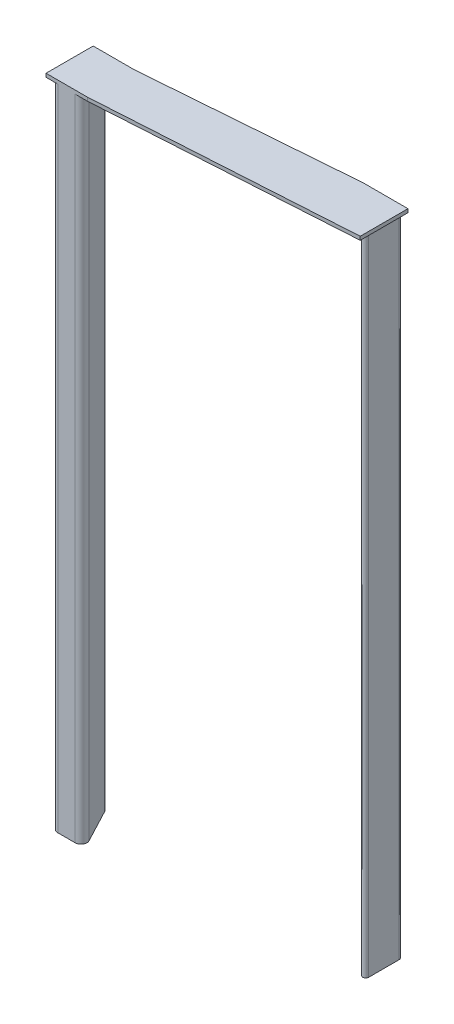
from build123d import *

# Parameters (mm, degrees)
BOSS_EXTRUDE1_DEPTH = 220
FILLET1_R           = 2
BOSS_EXTRUDE5_DEPTH = 220
SKETCH3_R           = 2
CUT_EXTRUDE1_DEPTH  = 5
SKETCH4_W           = 2.4
SKETCH4_H           = 2.4
CUT_EXTRUDE2_DEPTH  = 2
BOSS_EXTRUDE4_DEPTH = 1.2
FILLET2_R           = 1


with BuildPart() as part:
    # Sketch1 → Boss-Extrude1 (new body)
    with BuildSketch(Plane(origin=(0, 0, 0), x_dir=(1, 0, 0), z_dir=(0, 1, 0))):
        Polygon((0, 0), (0, 21.2), (11.2, 0), align=None)
    extrude(amount=BOSS_EXTRUDE1_DEPTH)

    # Fillet1
    fillet1_edges = [part.edges().sort_by_distance(p)[0] for p in [
        (0, 110, 0),
        (0, 110, -21.2),
        (11.2, 110, 0),
    ]]
    fillet(fillet1_edges, radius=FILLET1_R)


with BuildPart() as body_2:
    # Sketch5 → Boss-Extrude5 (new body)
    with BuildSketch(Plane.XZ):
        Polygon((86, -21.6), (97.2, -21.6), (97.2, -7.4), align=None)
    extrude(amount=-BOSS_EXTRUDE5_DEPTH)


with BuildPart() as cut_extrude1_tool:
    # Sketch3 → Cut-Extrude1 (new body)
    with BuildSketch(Plane.XZ):
        with Locations((4, -4)):
            Circle(SKETCH3_R)
        with Locations((93.6, -18)):
            Circle(SKETCH3_R)
    extrude(amount=-CUT_EXTRUDE1_DEPTH)


with BuildPart() as part_1:
    add(part.part)

    # Cut-Extrude1: cut by cut_extrude1_tool
    add(cut_extrude1_tool.part, mode=Mode.SUBTRACT)

    # Sketch4 → Cut-Extrude2 (cut)
    with BuildSketch(Plane.XZ):
        with Locations((3.2, -8.4)):
            Rectangle(SKETCH4_W, SKETCH4_H)
    extrude(amount=-CUT_EXTRUDE2_DEPTH, mode=Mode.SUBTRACT)

    # Sketch6 → Boss-Extrude4 (add)
    with BuildSketch(Plane(origin=(0, 220, 0), x_dir=(1, 0, 0), z_dir=(0, 1, 0))):
        Polygon((99.2, 21.6), (84, 21.6), (12, 16), (-2, 16), (-2, 0), (12, 0), (99.2, 5.4), align=None)
    extrude(amount=BOSS_EXTRUDE4_DEPTH)


with BuildPart() as body_2_1:
    add(body_2.part)

    # Cut-Extrude1: cut by cut_extrude1_tool
    add(cut_extrude1_tool.part, mode=Mode.SUBTRACT)

    # Fillet2
    fillet2_edges = [body_2_1.edges().sort_by_distance(p)[0] for p in [
        (97.2, 110, -7.4),
        (86, 110, -21.6),
        (97.2, 110, -21.6),
    ]]
    fillet(fillet2_edges, radius=FILLET2_R)


solid = Compound([part_1.part, body_2_1.part])
